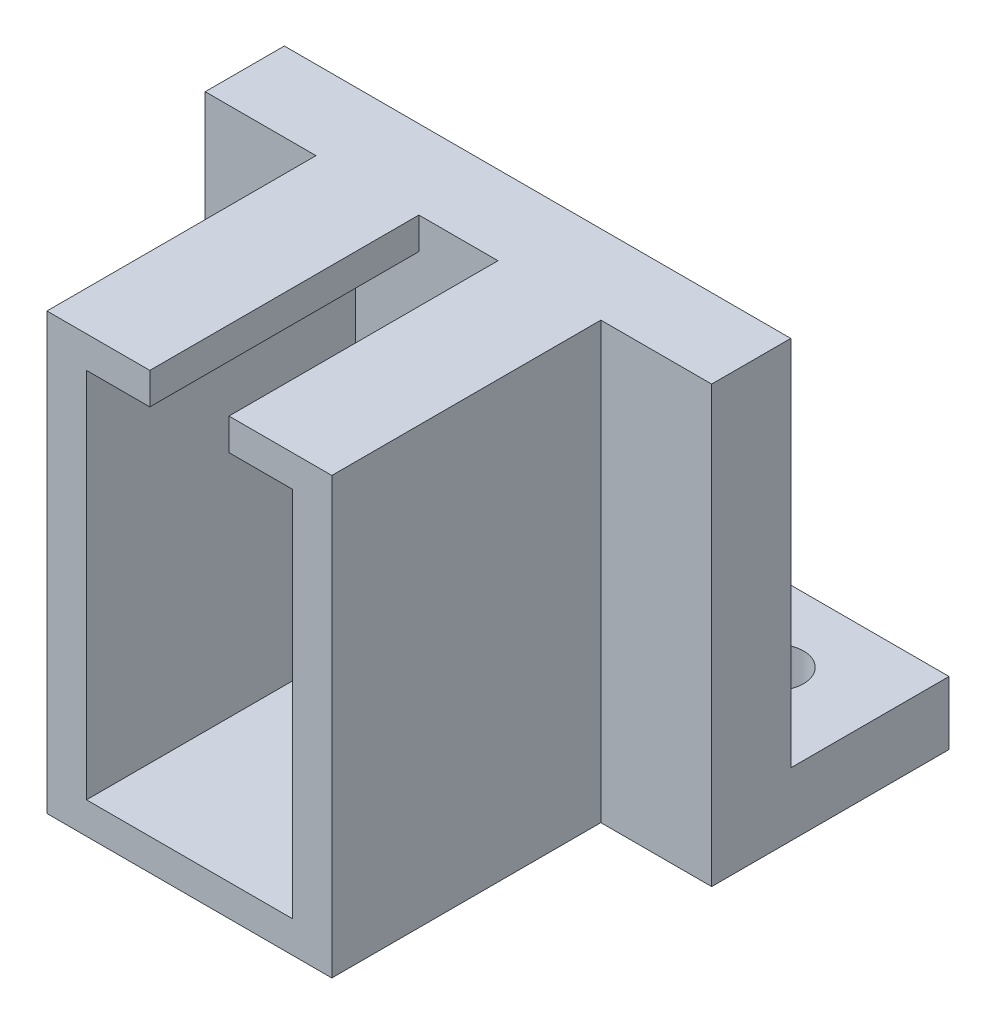
from build123d import *

# Parameters (mm, degrees)
SKETCH1_W                = 32
SKETCH1_H                = 15
BOSS_EXTRUDE1_DEPTH      = 4
BOSS_EXTRUDE2_START      = 4
SKETCH1_3_W              = 32
SKETCH1_3_H              = 5
BOSS_EXTRUDE2_DEPTH      = 23.5
BOSS_EXTRUDE3_DEPTH      = 17
M3_CLEARANCE_HOLE1_D     = 3.6
M3_CLEARANCE_HOLE1_DEPTH = 10
M3_CLEARANCE_HOLE1_TIP   = 1.081549114


with BuildPart() as part:
    # Sketch1 → Boss-Extrude1 (new body)
    with BuildSketch(Plane(origin=(0, 0, 0), x_dir=(1, 0, 0), z_dir=(0, 1, 0))):
        with Locations((0, 2.5)):
            Rectangle(SKETCH1_W, SKETCH1_H)
    extrude(amount=BOSS_EXTRUDE1_DEPTH)

    # Sketch1_3 → Boss-Extrude2 (add)
    with BuildSketch(Plane(origin=(0, 0, 0), x_dir=(1, 0, 0), z_dir=(0, 1, 0)).offset(BOSS_EXTRUDE2_START)):
        with Locations((0, -2.5)):
            Rectangle(SKETCH1_3_W, SKETCH1_3_H)
    extrude(amount=BOSS_EXTRUDE2_DEPTH)

    # Sketch2 → Boss-Extrude3 (add)
    with BuildSketch(Plane.XY.offset(5)):
        Polygon((-6.5, 2), (-6.5, 25.5), (-2.5, 25.5), (-2.5, 27.5), (-9, 27.5), (-9, 0), (9, 0), (9, 27.5), (2.5, 27.5), (2.5, 25.5), (6.5, 25.5), (6.5, 2), align=None)
    extrude(amount=BOSS_EXTRUDE3_DEPTH)

    # M3 Clearance Hole1
    with Locations(Plane(origin=(0, 4, 0), x_dir=(1, 0, 0), z_dir=(0, 1, 0))):
        with Locations((-10, 5), (10, 5)):
            Hole(M3_CLEARANCE_HOLE1_D / 2, depth=M3_CLEARANCE_HOLE1_DEPTH)
            with Locations((0, 0, -(M3_CLEARANCE_HOLE1_DEPTH + M3_CLEARANCE_HOLE1_TIP / 2))):  # 118° drill point
                Cone(0, M3_CLEARANCE_HOLE1_D / 2, M3_CLEARANCE_HOLE1_TIP, mode=Mode.SUBTRACT)


solid = part.part
